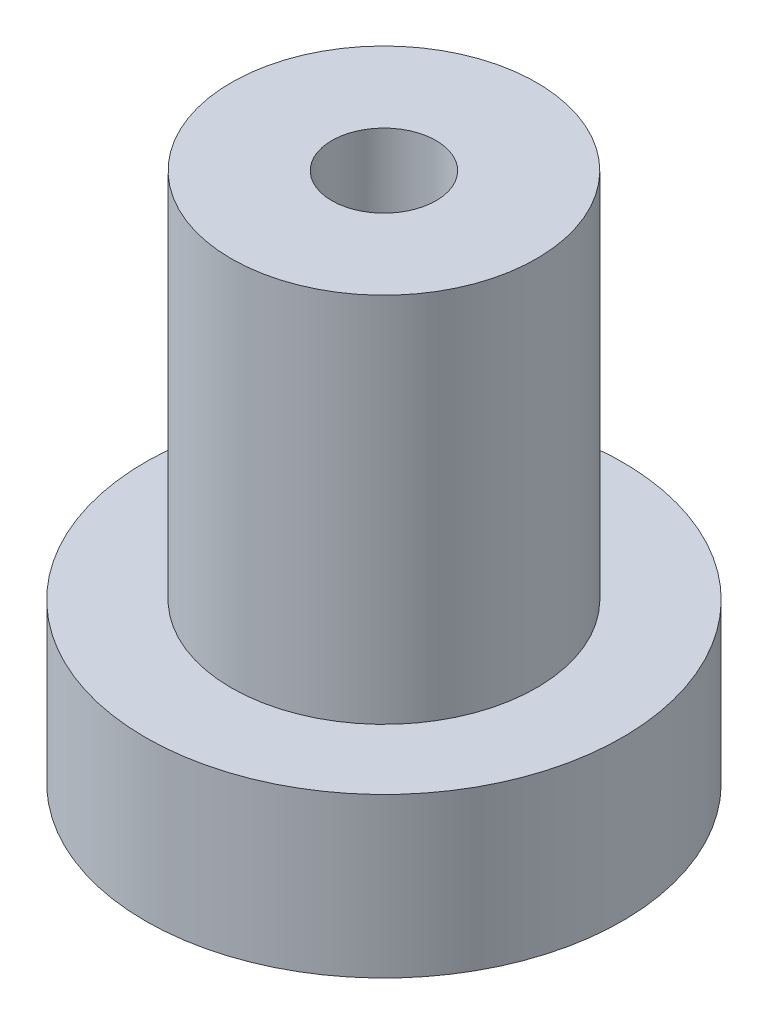
from build123d import *

# Parameters (mm, degrees)
F_8_32_TAPPED_HOLE1_D = 4.1656
CUT_EXTRUDE1_DEPTH    = 3.556


with BuildPart() as part:
    # Sketch3 → Revolve1 (revolve)
    with BuildSketch(Plane.XY):
        Polygon((0, 0), (9.525, 0), (9.525, 6.35), (6.096, 6.35), (6.096, 21.193), (0, 21.193), align=None)
    revolve(axis=Axis((0, 21.193, 0), (0, -1, 0)))

    # #8-32 Tapped Hole1 (through all)
    with Locations(Plane(origin=(0, 21.193, 0), x_dir=(1, 0, 0), z_dir=(0, 1, 0))):
        with Locations((0, 0)):
            Hole(F_8_32_TAPPED_HOLE1_D / 2)

    # Sketch6 → Cut-Extrude1 (cut)
    with BuildSketch(Plane.XZ):
        Polygon((2.369915953, 4.552749906), (-2.757839099, 4.328782373), (-5.127755052, -0.223967533), (-2.369915953, -4.552749906), (2.757839099, -4.328782373), (5.127755052, 0.223967533), align=None)
    extrude(amount=-CUT_EXTRUDE1_DEPTH, mode=Mode.SUBTRACT)


solid = part.part
